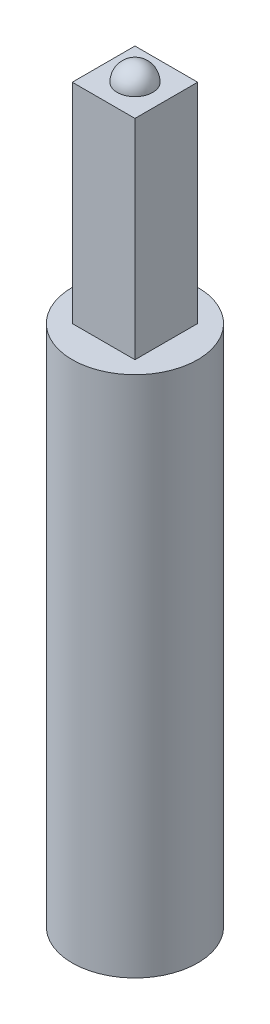
from build123d import *

# Parameters (mm, degrees)
SKETCH1_R           = 30
BOSS_EXTRUDE1_DEPTH = 250
BOSS_EXTRUDE2_DEPTH = 100


with BuildPart() as part:
    # Sketch1 → Boss-Extrude1 (new body)
    with BuildSketch(Plane(origin=(0, 0, 0), x_dir=(1, 0, 0), z_dir=(0, 1, 0))):
        Circle(SKETCH1_R)
    extrude(amount=BOSS_EXTRUDE1_DEPTH)

    # Sketch3 → Boss-Extrude2 (add)
    with BuildSketch(Plane(origin=(0, 250, 0), x_dir=(1, 0, 0), z_dir=(0, 1, 0))):
        Polygon((-15, 0.769018566), (-15, 15), (15, 15), (15, -15), (-15, -15), align=None)
    extrude(amount=BOSS_EXTRUDE2_DEPTH)

    # Sketch4 → Revolve1 (revolve)
    with BuildSketch(Plane(origin=(0, 350, 0), x_dir=(1, 0, 0), z_dir=(0, 1, 0))):
        with BuildLine():
            Line((0, 8.5), (0, -8.5))
            ThreePointArc((0, -8.5), (8.5, 0), (0, 8.5))
        make_face()
    revolve(axis=Axis((0, 350, -8.5), (0, 0, 1)))


solid = part.part
